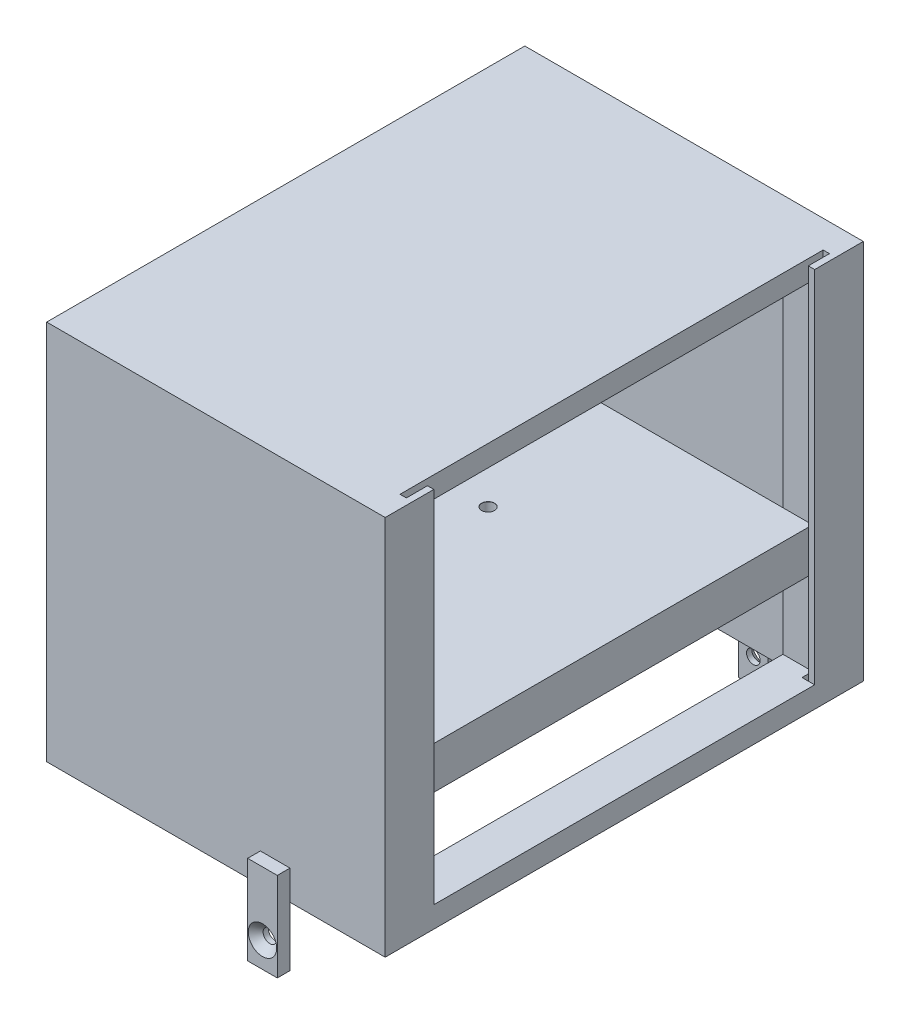
from build123d import *

# Parameters (mm, degrees)
SKETCH1_W                                            = 80
SKETCH1_H                                            = 113
BOSS_EXTRUDE1_DEPTH                                  = 90
SKETCH3_W                                            = 55
SKETCH3_H                                            = 100
CUT_EXTRUDE2_DEPTH                                   = 87
SKETCH4_W                                            = 95
SKETCH4_H                                            = 80
CUT_EXTRUDE3_DEPTH                                   = 77
SKETCH6_W                                            = 95
SKETCH6_H                                            = 10
BOSS_EXTRUDE4_DEPTH                                  = 77
CUT_EXTRUDE4_DEPTH                                   = 91
F_3_0_3_DIAMETER_HOLE1_D                             = 3
F_3_0_3_DIAMETER_HOLE1_DEPTH                         = 5.098709071
F_3_0_3_DIAMETER_HOLE1_CSINK_D                       = 3.05
F_3_0_3_DIAMETER_HOLE1_CSINK_ANGLE                   = 90
F_3_0_3_DIAMETER_HOLE1_TIP                           = 0.901290929
SKETCH11_W                                           = 90
SKETCH11_H                                           = 5
BOSS_EXTRUDE5_DEPTH                                  = 3
SKETCH12_W                                           = 7
SKETCH12_H                                           = 21
BOSS_EXTRUDE6_DEPTH                                  = 3
SKETCH13_W                                           = 7
SKETCH13_H                                           = 21
BOSS_EXTRUDE7_DEPTH                                  = 3
CSK_FOR_M3_HEX_SOCKET_COUNTERSUNK_CAP_SC_D           = 3.2
CSK_FOR_M3_HEX_SOCKET_COUNTERSUNK_CAP_SC_DEPTH       = 7.23862301
CSK_FOR_M3_HEX_SOCKET_COUNTERSUNK_CAP_SC_CSINK_D     = 6.72
CSK_FOR_M3_HEX_SOCKET_COUNTERSUNK_CAP_SC_CSINK_ANGLE = 90
CSK_FOR_M3_HEX_SOCKET_COUNTERSUNK_CAP_SC_TIP         = 0.96137699
CSK_FOR_M3_HEX_SOCKET_COUNTERSUNK_CA_2_D             = 3.2
CSK_FOR_M3_HEX_SOCKET_COUNTERSUNK_CA_2_DEPTH         = 7.23862301
CSK_FOR_M3_HEX_SOCKET_COUNTERSUNK_CA_2_CSINK_D       = 6.72
CSK_FOR_M3_HEX_SOCKET_COUNTERSUNK_CA_2_CSINK_ANGLE   = 90
CSK_FOR_M3_HEX_SOCKET_COUNTERSUNK_CA_2_TIP           = 0.96137699


with BuildPart() as part:
    # Sketch1 → Boss-Extrude1 (new body)
    with BuildSketch(Plane(origin=(0, 0, 0), x_dir=(1, 0, 0), z_dir=(0, 1, 0))):
        Rectangle(SKETCH1_W, SKETCH1_H)
    extrude(amount=BOSS_EXTRUDE1_DEPTH)

    # Sketch3 → Cut-Extrude2 (cut)
    with BuildSketch(Plane.XZ):
        with Locations((2.5, 0)):
            Rectangle(SKETCH3_W, SKETCH3_H)
    extrude(amount=-CUT_EXTRUDE2_DEPTH, mode=Mode.SUBTRACT)

    # Sketch4 → Cut-Extrude3 (cut)
    with BuildSketch(Plane.ZY.offset(40)):
        with Locations((0, 45)):
            Rectangle(SKETCH4_W, SKETCH4_H)
    extrude(amount=-CUT_EXTRUDE3_DEPTH, mode=Mode.SUBTRACT)

    # Sketch6 → Boss-Extrude4 (add)
    with BuildSketch(Plane.ZY.offset(-37)):
        with Locations((0, 30)):
            Rectangle(SKETCH6_W, SKETCH6_H)
    extrude(amount=BOSS_EXTRUDE4_DEPTH)

    # Sketch7 → Cut-Extrude4 (cut, through all)
    with BuildSketch(Plane(origin=(0, 0, 0), x_dir=(1, 0, 0), z_dir=(0, 1, 0))):
        Polygon((40, 45), (38.5, 45), (38.5, 50), (37, 50), (37, -50), (38.5, -50), (38.5, -45), (40, -45), align=None)
    extrude(amount=CUT_EXTRUDE4_DEPTH, mode=Mode.SUBTRACT)

    # Ø3.0 (3) Diameter Hole1
    with Locations(Plane(origin=(0, 35, 0), x_dir=(1, 0, 0), z_dir=(0, 1, 0))):
        with Locations((-5.02, -17.05), (-5.02, 12.84), (-29.68, 12.84), (-29.68, -17.05)):
            CounterSinkHole(F_3_0_3_DIAMETER_HOLE1_D / 2, F_3_0_3_DIAMETER_HOLE1_CSINK_D / 2, depth=F_3_0_3_DIAMETER_HOLE1_DEPTH, counter_sink_angle=F_3_0_3_DIAMETER_HOLE1_CSINK_ANGLE)
            with Locations((0, 0, -(F_3_0_3_DIAMETER_HOLE1_DEPTH + F_3_0_3_DIAMETER_HOLE1_TIP / 2))):  # 118° drill point
                Cone(0, F_3_0_3_DIAMETER_HOLE1_D / 2, F_3_0_3_DIAMETER_HOLE1_TIP, mode=Mode.SUBTRACT)

    # Sketch11 → Boss-Extrude5 (add, through all)
    with BuildSketch(Plane(origin=(37, 0, 0), x_dir=(0, 0, -1), z_dir=(1, 0, 0))):
        with Locations((0, 2.5)):
            Rectangle(SKETCH11_W, SKETCH11_H)
    extrude(amount=BOSS_EXTRUDE5_DEPTH)

    # Sketch12 → Boss-Extrude6 (add)
    with BuildSketch(Plane.XY.offset(56.5)):
        with Locations((14, -3.5)):
            Rectangle(SKETCH12_W, SKETCH12_H)
    extrude(amount=BOSS_EXTRUDE6_DEPTH)

    # Sketch13 → Boss-Extrude7 (add)
    with BuildSketch(Plane(origin=(0, 0, -56.5), x_dir=(-1, 0, 0), z_dir=(0, 0, -1))):
        with Locations((-14, -3.5)):
            Rectangle(SKETCH13_W, SKETCH13_H)
    extrude(amount=BOSS_EXTRUDE7_DEPTH)

    # CSK for M3 Hex Socket Countersunk Cap Sc
    with Locations(Plane(origin=(0, 0, -59.5), x_dir=(-1, 0, 0), z_dir=(0, 0, -1))):
        with Locations((-14, -8)):
            CounterSinkHole(CSK_FOR_M3_HEX_SOCKET_COUNTERSUNK_CAP_SC_D / 2, CSK_FOR_M3_HEX_SOCKET_COUNTERSUNK_CAP_SC_CSINK_D / 2, depth=CSK_FOR_M3_HEX_SOCKET_COUNTERSUNK_CAP_SC_DEPTH, counter_sink_angle=CSK_FOR_M3_HEX_SOCKET_COUNTERSUNK_CAP_SC_CSINK_ANGLE)
            with Locations((0, 0, -(CSK_FOR_M3_HEX_SOCKET_COUNTERSUNK_CAP_SC_DEPTH + CSK_FOR_M3_HEX_SOCKET_COUNTERSUNK_CAP_SC_TIP / 2))):  # 118° drill point
                Cone(0, CSK_FOR_M3_HEX_SOCKET_COUNTERSUNK_CAP_SC_D / 2, CSK_FOR_M3_HEX_SOCKET_COUNTERSUNK_CAP_SC_TIP, mode=Mode.SUBTRACT)

    # CSK for M3 Hex Socket Countersunk Ca 2
    with Locations(Plane.XY.offset(59.5)):
        with Locations((14, -8)):
            CounterSinkHole(CSK_FOR_M3_HEX_SOCKET_COUNTERSUNK_CA_2_D / 2, CSK_FOR_M3_HEX_SOCKET_COUNTERSUNK_CA_2_CSINK_D / 2, depth=CSK_FOR_M3_HEX_SOCKET_COUNTERSUNK_CA_2_DEPTH, counter_sink_angle=CSK_FOR_M3_HEX_SOCKET_COUNTERSUNK_CA_2_CSINK_ANGLE)
            with Locations((0, 0, -(CSK_FOR_M3_HEX_SOCKET_COUNTERSUNK_CA_2_DEPTH + CSK_FOR_M3_HEX_SOCKET_COUNTERSUNK_CA_2_TIP / 2))):  # 118° drill point
                Cone(0, CSK_FOR_M3_HEX_SOCKET_COUNTERSUNK_CA_2_D / 2, CSK_FOR_M3_HEX_SOCKET_COUNTERSUNK_CA_2_TIP, mode=Mode.SUBTRACT)


solid = part.part
